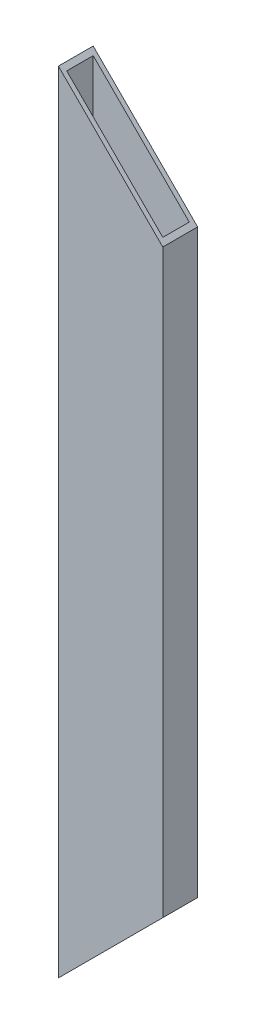
from build123d import *

# Parameters (mm, degrees)
SKETCH1_W               = 76.2
SKETCH1_H               = 25.4
SKETCH1_W_2             = 70.104
SKETCH1_H_2             = 19.304
BOSS_EXTRUDE1_DEPTH     = 500
SKETCH3_W               = 76.2
SKETCH3_H               = 25.4
SKETCH3_W_2             = 70.104
SKETCH3_H_2             = 19.304
BOSS_EXTRUDE2_DEPTH     = 38.1
SKETCH4_W               = 76.2
SKETCH4_H               = 25.4
SKETCH4_W_2             = 70.104
SKETCH4_H_2             = 19.304
BOSS_EXTRUDE3_DEPTH     = 38.1
CUT_EXTRUDE1_DEPTH      = 13.7
CUT_EXTRUDE1_DEPTH_BACK = 13.7


with BuildPart() as part:
    # Sketch1 → Boss-Extrude1 (new body)
    with BuildSketch(Plane(origin=(0, 0, 0), x_dir=(1, 0, 0), z_dir=(0, 1, 0))):
        Rectangle(SKETCH1_W, SKETCH1_H)
        Rectangle(SKETCH1_W_2, SKETCH1_H_2, mode=Mode.SUBTRACT)
    extrude(amount=BOSS_EXTRUDE1_DEPTH)

    # Sketch3 → Boss-Extrude2 (add)
    with BuildSketch(Plane(origin=(0, 500, 0), x_dir=(1, 0, 0), z_dir=(0, 1, 0))):
        Rectangle(SKETCH3_W, SKETCH3_H)
        Rectangle(SKETCH3_W_2, SKETCH3_H_2, mode=Mode.SUBTRACT)
    extrude(amount=BOSS_EXTRUDE2_DEPTH)

    # Sketch4 → Boss-Extrude3 (add)
    with BuildSketch(Plane.XZ):
        Rectangle(SKETCH4_W, SKETCH4_H)
        Rectangle(SKETCH4_W_2, SKETCH4_H_2, mode=Mode.SUBTRACT)
    extrude(amount=BOSS_EXTRUDE3_DEPTH)

    # Sketch5 → Cut-Extrude1 (cut, two sides)
    with BuildSketch(Plane.XY) as cut_extrude1_sk:
        Polygon((73.806196074, 73.806196074), (-85.540329475, -85.540329475), (73.806196074, -85.540329475), align=None)
        Polygon((59.635828429, 440.364171571), (-60.966910251, 560.966910251), (59.635828429, 560.966910251), align=None)
    extrude(amount=CUT_EXTRUDE1_DEPTH, mode=Mode.SUBTRACT)
    extrude(cut_extrude1_sk.sketch, amount=-CUT_EXTRUDE1_DEPTH_BACK, mode=Mode.SUBTRACT)


solid = part.part
